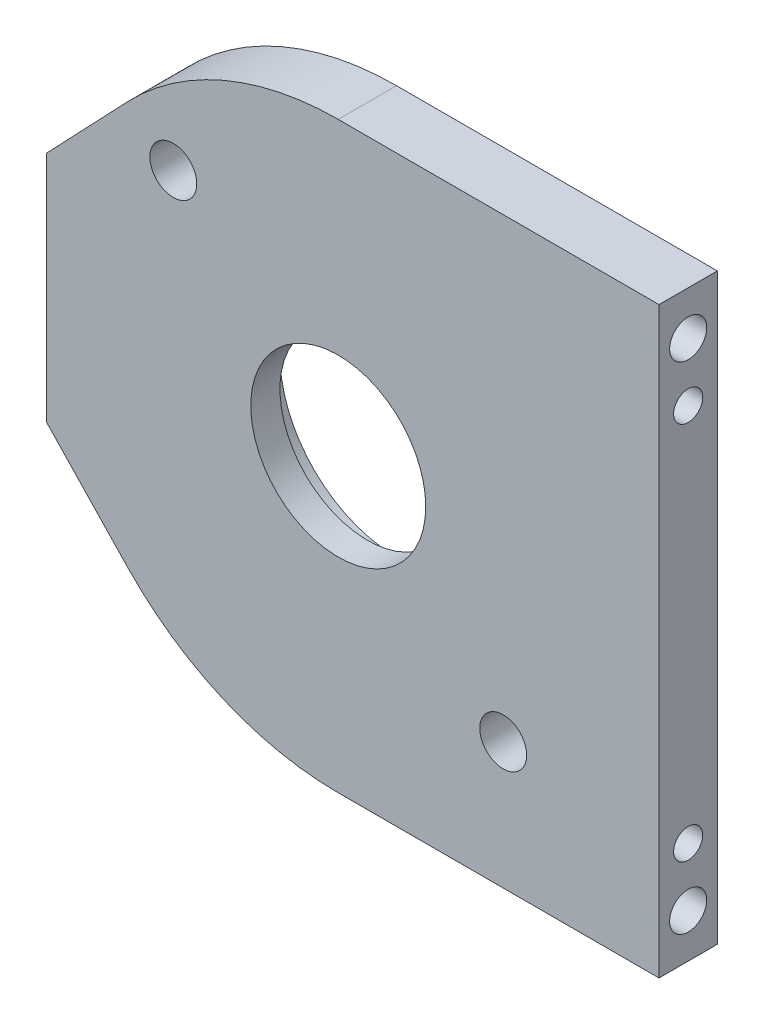
from build123d import *

# Parameters (mm, degrees)
SKETCH1_R                                  = 9.525
BOSS_EXTRUDE1_DEPTH                        = 6.35
F_10_CLEARANCE_HOLE1_D                     = 5.1054
F_1_8_0_125_TRANSITIONAL_DOWEL_HOLE1_D     = 3.175
F_1_8_0_125_TRANSITIONAL_DOWEL_HOLE1_DEPTH = 10.16
F_1_8_0_125_TRANSITIONAL_DOWEL_HOLE1_TIP   = 0.953866233
SKETCH6_R                                  = 12.7
CUT_EXTRUDE1_DEPTH                         = 3.175
F_10_32_TAPPED_HOLE1_D                     = 4.0386
F_10_32_TAPPED_HOLE1_DEPTH                 = 15.748
F_10_32_TAPPED_HOLE1_TIP                   = 1.213317848
F_1_8_0_125_PRESS_DOWEL_HOLE1_D            = 3.175
F_1_8_0_125_PRESS_DOWEL_HOLE1_DEPTH        = 6.35
F_1_8_0_125_PRESS_DOWEL_HOLE1_TIP          = 0.953866233
F_10_32_TAPPED_HOLE2_D                     = 4.0386
F_10_32_TAPPED_HOLE2_DEPTH                 = 15.748
F_10_32_TAPPED_HOLE2_TIP                   = 1.213317848


with BuildPart() as part:
    # Sketch1 → Boss-Extrude1 (new body)
    with BuildSketch(Plane.XY):
        with BuildLine():
            Line((34.925, 31.75), (34.925, -31.75))
            Line((34.925, -31.75), (0, -31.75))
            ThreePointArc((0, -31.75), (-12.50693773, -29.182854703), (-22.99137931, -21.896551724))
            Line((-22.99137931, -21.896551724), (-31.75, -12.7))
            Line((-31.75, -12.7), (-31.75, 12.7))
            Line((-31.75, 12.7), (-22.99137931, 21.896551724))
            ThreePointArc((-22.99137931, 21.896551724), (-12.50693773, 29.182854703), (0, 31.75))
            Line((0, 31.75), (34.925, 31.75))
        make_face()
        Circle(SKETCH1_R, mode=Mode.SUBTRACT)
    extrude(amount=BOSS_EXTRUDE1_DEPTH)

    # #10 Clearance Hole1 (through all)
    with Locations(Plane.XY.offset(6.35)):
        with Locations((17.960512242, -17.960512242), (-17.960512242, 17.960512242)):
            Hole(F_10_CLEARANCE_HOLE1_D / 2)

    # 1/8 (0.125) Transitional Dowel Hole1
    with Locations(Plane(origin=(34.925, 0, 0), x_dir=(0, 0, -1), z_dir=(1, 0, 0))):
        with Locations((-3.175, 20.6375), (-3.175, -20.6375)):
            Hole(F_1_8_0_125_TRANSITIONAL_DOWEL_HOLE1_D / 2, depth=F_1_8_0_125_TRANSITIONAL_DOWEL_HOLE1_DEPTH)
            with Locations((0, 0, -(F_1_8_0_125_TRANSITIONAL_DOWEL_HOLE1_DEPTH + F_1_8_0_125_TRANSITIONAL_DOWEL_HOLE1_TIP / 2))):  # 118° drill point
                Cone(0, F_1_8_0_125_TRANSITIONAL_DOWEL_HOLE1_D / 2, F_1_8_0_125_TRANSITIONAL_DOWEL_HOLE1_TIP, mode=Mode.SUBTRACT)

    # Sketch6 → Cut-Extrude1 (cut)
    with BuildSketch(Plane.XY):
        Circle(SKETCH6_R)
    extrude(amount=CUT_EXTRUDE1_DEPTH, mode=Mode.SUBTRACT)

    # #10-32 Tapped Hole1
    with Locations(Plane(origin=(34.925, 0, 0), x_dir=(0, 0, -1), z_dir=(1, 0, 0))):
        with Locations((-3.175, 26.9875), (-3.175, -26.9875)):
            Hole(F_10_32_TAPPED_HOLE1_D / 2, depth=F_10_32_TAPPED_HOLE1_DEPTH)
            with Locations((0, 0, -(F_10_32_TAPPED_HOLE1_DEPTH + F_10_32_TAPPED_HOLE1_TIP / 2))):  # 118° drill point
                Cone(0, F_10_32_TAPPED_HOLE1_D / 2, F_10_32_TAPPED_HOLE1_TIP, mode=Mode.SUBTRACT)

    # 1/8 (0.125) Press Dowel Hole1
    with Locations(Plane.ZY.offset(31.75)):
        with Locations((3.175, 7.9375), (3.175, -7.9375)):
            Hole(F_1_8_0_125_PRESS_DOWEL_HOLE1_D / 2, depth=F_1_8_0_125_PRESS_DOWEL_HOLE1_DEPTH)
            with Locations((0, 0, -(F_1_8_0_125_PRESS_DOWEL_HOLE1_DEPTH + F_1_8_0_125_PRESS_DOWEL_HOLE1_TIP / 2))):  # 118° drill point
                Cone(0, F_1_8_0_125_PRESS_DOWEL_HOLE1_D / 2, F_1_8_0_125_PRESS_DOWEL_HOLE1_TIP, mode=Mode.SUBTRACT)

    # #10-32 Tapped Hole2
    with Locations(Plane.ZY.offset(31.75)):
        with Locations((3.175, 0)):
            Hole(F_10_32_TAPPED_HOLE2_D / 2, depth=F_10_32_TAPPED_HOLE2_DEPTH)
            with Locations((0, 0, -(F_10_32_TAPPED_HOLE2_DEPTH + F_10_32_TAPPED_HOLE2_TIP / 2))):  # 118° drill point
                Cone(0, F_10_32_TAPPED_HOLE2_D / 2, F_10_32_TAPPED_HOLE2_TIP, mode=Mode.SUBTRACT)


solid = part.part
